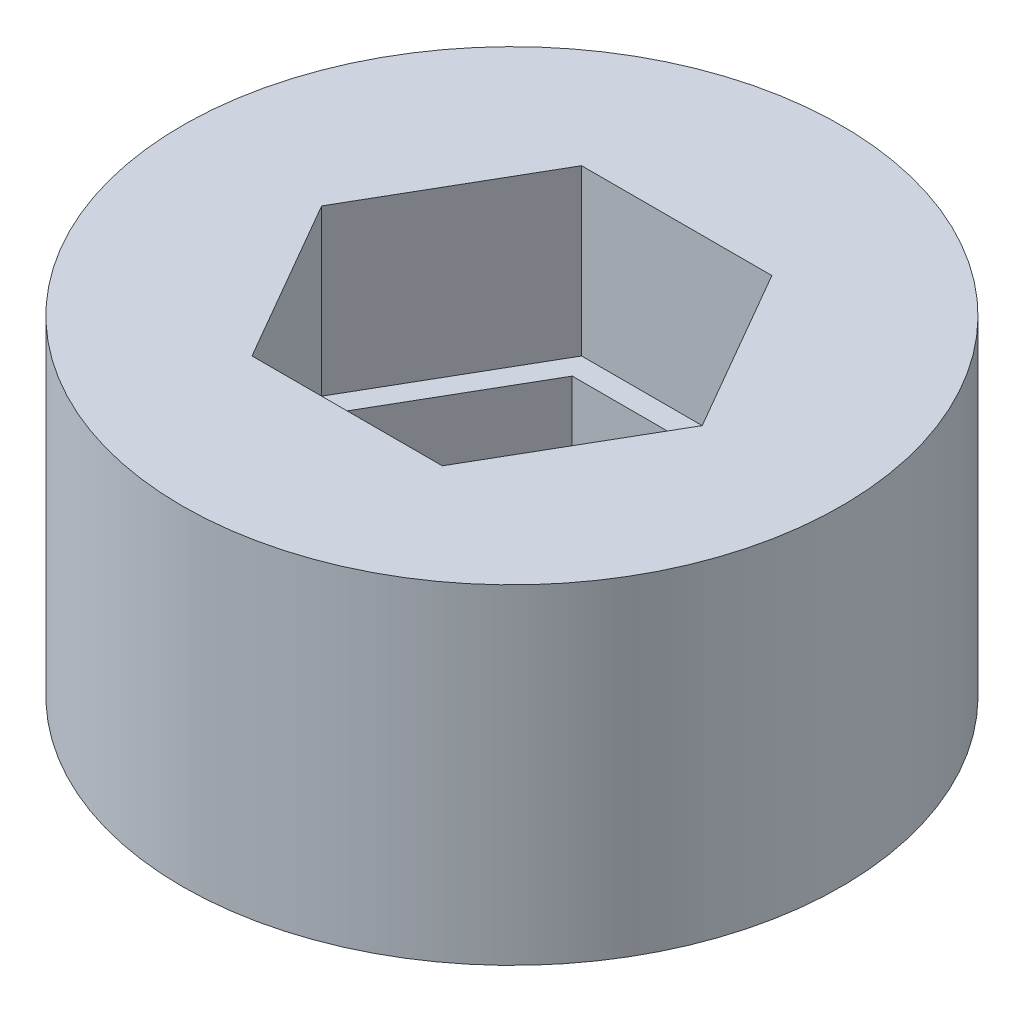
from build123d import *

# Parameters (mm, degrees)
SKETCH1_R           = 6.35
BOSS_EXTRUDE1_DEPTH = 3.175
SKETCH2_R           = 6.35
BOSS_EXTRUDE2_DEPTH = 3.175


with BuildPart() as part:
    # Sketch1 → Boss-Extrude1 (new body)
    with BuildSketch(Plane(origin=(0, 0, 0), x_dir=(1, 0, 0), z_dir=(0, 1, 0))):
        Circle(SKETCH1_R)
        Polygon((1.5875, 2.749630657), (-1.5875, 2.749630657), (-3.175, 0), (-1.5875, -2.749630657), (1.5875, -2.749630657), (3.175, 0), align=None, mode=Mode.SUBTRACT)
    extrude(amount=BOSS_EXTRUDE1_DEPTH)

    # Sketch2 → Boss-Extrude2 (add)
    with BuildSketch(Plane(origin=(0, 3.175, 0), x_dir=(1, 0, 0), z_dir=(0, 1, 0))):
        Circle(SKETCH2_R)
        Polygon((1.833087105, 3.175), (-1.833087105, 3.175), (-3.666174209, 0), (-1.833087105, -3.175), (1.833087105, -3.175), (3.666174209, 0), align=None, mode=Mode.SUBTRACT)
    extrude(amount=BOSS_EXTRUDE2_DEPTH)


solid = part.part
